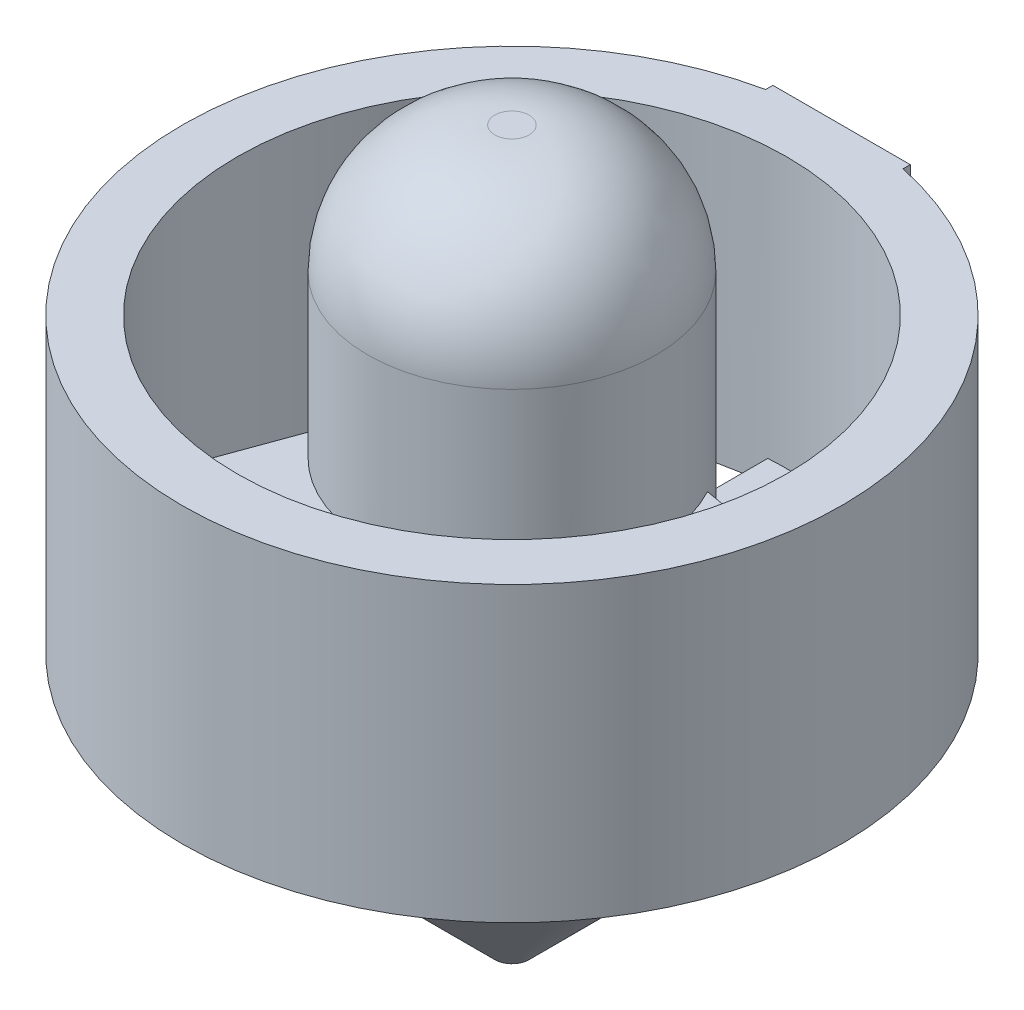
from build123d import *

# Parameters (mm, degrees)
BOSS_EXTRUDE1_DEPTH      = 20.32
BOSS_EXTRUDE1_DEPTH_BACK = 20.32
SKETCH1_R                = 45.72
SKETCH1_R_2              = 38.1
BOSS_EXTRUDE2_DEPTH      = 43.18
BOSS_EXTRUDE2_DEPTH_BACK = 55.88
SKETCH1_4_R              = 20.0025
CHAMFER1_SIZE            = 17.62
FILLET1_R                = 17.62
BOSS_EXTRUDE3_DEPTH      = 3.175
BOSS_EXTRUDE4_DEPTH      = 3.175
SKETCH4_W                = 19.05
SKETCH4_H                = 40.64
BOSS_EXTRUDE5_DEPTH      = 3.175


with BuildPart() as part:
    # Sketch1 → Boss-Extrude1 (new, two sides: drawn at the far end of the back side and taken through both)
    with BuildSketch(Plane(origin=(0, 0, 0), x_dir=(1, 0, 0), z_dir=(0, 1, 0)).offset(-BOSS_EXTRUDE1_DEPTH_BACK)):
        Circle(SKETCH1_R)
        Circle(SKETCH1_R_2, mode=Mode.SUBTRACT)
    extrude(amount=BOSS_EXTRUDE1_DEPTH + BOSS_EXTRUDE1_DEPTH_BACK)



with BuildPart() as body_2:
    # Sketch1_4 → Boss-Extrude2 (new, two sides: drawn at the far end of the back side and taken through both)
    with BuildSketch(Plane(origin=(0, 0, 0), x_dir=(1, 0, 0), z_dir=(0, 1, 0)).offset(-BOSS_EXTRUDE2_DEPTH_BACK)):
        Circle(SKETCH1_4_R)
    extrude(amount=BOSS_EXTRUDE2_DEPTH + BOSS_EXTRUDE2_DEPTH_BACK)

    # Chamfer1
    chamfer1_edges = [body_2.edges().sort_by_distance(p)[0] for p in [
        (-20.0025, -55.88, 0),
    ]]
    chamfer(chamfer1_edges, length=CHAMFER1_SIZE)

    # Fillet1
    fillet1_edges = [body_2.edges().sort_by_distance(p)[0] for p in [
        (-20.0025, 43.18, 0),
    ]]
    fillet(fillet1_edges, radius=FILLET1_R)

    # Sketch2 → Boss-Extrude3 (add)
    with BuildSketch(Plane(origin=(0, 0, 0), x_dir=(1, 0, 0), z_dir=(0, 1, 0))):
        Polygon((17.58904151, 9.525), (35.36904151, 6.389906283), (35.36904151, -6.389906283), (17.58904151, -9.525), (17.58904151, 0), align=None)
        Polygon((-23.218341924, -27.435535314), (-17.043412726, -10.470056776), (-8.794520755, -15.232556776), (-0.545628784, -19.995056776), (-12.150699586, -33.825441597), align=None)
        Polygon((-12.150699586, 33.825441597), (-0.545628784, 19.995056776), (-8.794520755, 15.232556776), (-17.043412726, 10.470056776), (-23.218341924, 27.435535314), align=None)
    extrude(amount=BOSS_EXTRUDE3_DEPTH)


with BuildPart() as part_1:
    add(part.part)

    add(body_2.part)  # Boss-Extrude4 merges body 2
    # Sketch3 → Boss-Extrude4 (add)
    with BuildSketch(Plane.XZ.offset(20.32)):
        with BuildLine():
            ThreePointArc((38.01523905, -2.54), (38.1, 0), (38.01523905, 2.54))
            Line((38.01523905, 2.54), (2.54, 2.54))
            Line((2.54, 2.54), (2.54, -2.54))
            Line((2.54, -2.54), (38.01523905, -2.54))
        make_face()
        with BuildLine():
            Line((2.54, -38.01523905), (2.54, -2.54))
            Line((2.54, -2.54), (-2.54, -2.54))
            Line((-2.54, -2.54), (-2.54, -38.01523905))
            ThreePointArc((-2.54, -38.01523905), (0, -38.1), (2.54, -38.01523905))
        make_face()
        with BuildLine():
            Line((-2.54, 2.54), (2.54, 2.54))
            Line((2.54, 2.54), (2.54, 38.01523905))
            ThreePointArc((2.54, 38.01523905), (0, 38.1), (-2.54, 38.01523905))
            Line((-2.54, 38.01523905), (-2.54, 2.54))
        make_face()
        with BuildLine():
            Line((-2.54, -2.54), (-2.54, 2.54))
            Line((-2.54, 2.54), (-38.01523905, 2.54))
            ThreePointArc((-38.01523905, 2.54), (-38.1, 0), (-38.01523905, -2.54))
            Line((-38.01523905, -2.54), (-2.54, -2.54))
        make_face()
    extrude(amount=-BOSS_EXTRUDE4_DEPTH)

    # Sketch4 → Boss-Extrude5 (add)
    with BuildSketch(Plane(origin=(0, 0, -45.72), x_dir=(-1, 0, 0), z_dir=(0, 0, -1))):
        Rectangle(SKETCH4_W, SKETCH4_H)
    extrude(amount=-BOSS_EXTRUDE5_DEPTH)


solid = part_1.part
